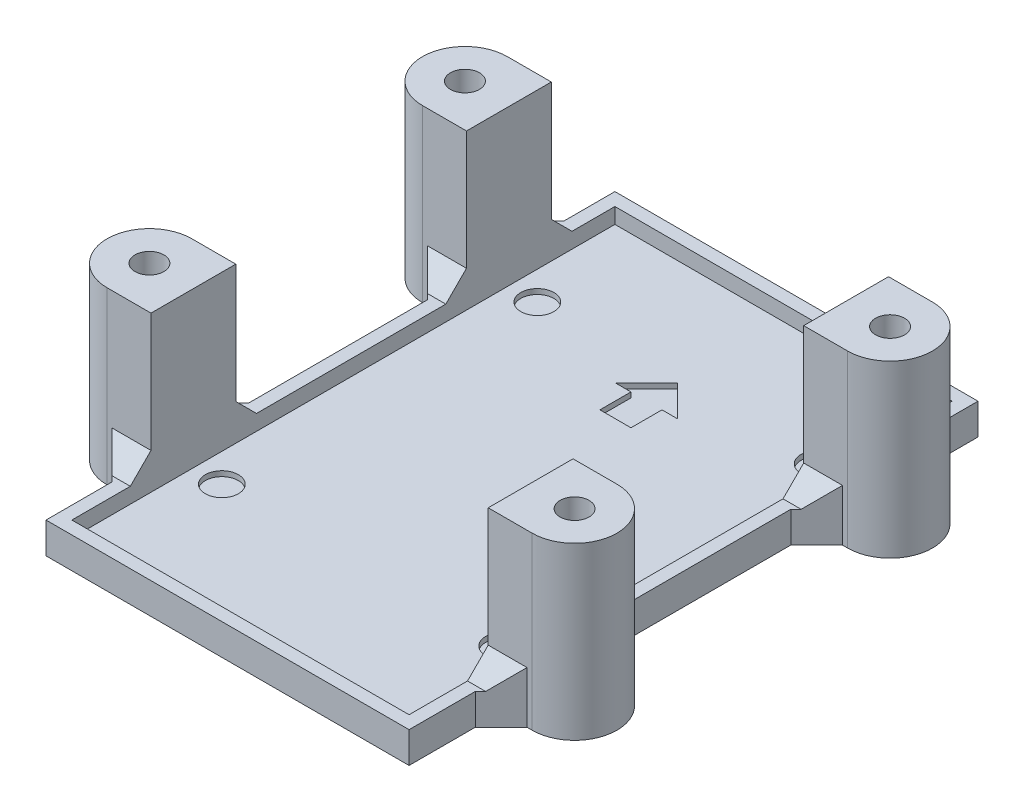
from build123d import *

# Parameters (mm, degrees)
SKETCH2_R               = 1.4
BOSS_EXTRUDE1_DEPTH     = 1.5
SKETCH5_R               = 1.6
CUT_EXTRUDE1_DEPTH      = 0.5
SKETCH3_R               = 1.4
SKETCH3_W               = 32.6
SKETCH3_H               = 52.5
BOSS_EXTRUDE2_DEPTH     = 1.5
SKETCH4_R               = 1.4
BOSS_EXTRUDE3_DEPTH     = 13.5
CHAMFER1_SIZE           = 2
CUT_EXTRUDE2_DEPTH      = 1
CUT_EXTRUDE2_DEPTH_BACK = 2.5


with BuildPart() as part:
    # Sketch2 → Boss-Extrude1 (new body)
    with BuildSketch(Plane(origin=(0, 0, 0), x_dir=(1, 0, 0), z_dir=(0, 1, 0))):
        with BuildLine():
            Line((-1.5, -1.5), (-1.5, 4.9))
            Line((-1.5, 4.9), (-4, 7.4))
            Line((-4, 7.4), (-4.5, 7.4))
            ThreePointArc((-4.5, 7.4), (-8.6, 11.5), (-4.5, 15.6))
            Line((-4.5, 15.6), (-4, 15.6))
            Line((-4, 15.6), (-1.5, 18.1))
            Line((-1.5, 18.1), (-1.5, 35.4))
            Line((-1.5, 35.4), (-4, 37.9))
            Line((-4, 37.9), (-4.5, 37.9))
            ThreePointArc((-4.5, 37.9), (-8.6, 42), (-4.5, 46.1))
            Line((-4.5, 46.1), (-4, 46.1))
            Line((-4, 46.1), (-1.5, 48.6))
            Line((-1.5, 48.6), (-1.5, 53.5))
            Line((-1.5, 53.5), (33.6, 53.5))
            Line((33.6, 53.5), (33.6, 48.6))
            Line((33.6, 48.6), (36.1, 46.1))
            Line((36.1, 46.1), (36.6, 46.1))
            ThreePointArc((36.6, 46.1), (40.7, 42), (36.6, 37.9))
            Line((36.6, 37.9), (36.1, 37.9))
            Line((36.1, 37.9), (33.6, 35.4))
            Line((33.6, 35.4), (33.6, 18.1))
            Line((33.6, 18.1), (36.1, 15.6))
            Line((36.1, 15.6), (36.6, 15.6))
            ThreePointArc((36.6, 15.6), (40.7, 11.5), (36.6, 7.4))
            Line((36.6, 7.4), (36.1, 7.4))
            Line((36.1, 7.4), (33.6, 4.9))
            Line((33.6, 4.9), (33.6, -1.5))
            Line((33.6, -1.5), (-1.5, -1.5))
        make_face()
        with Locations((-4.5, 42)):
            Circle(SKETCH2_R, mode=Mode.SUBTRACT)
        with Locations((-4.5, 11.5)):
            Circle(SKETCH2_R, mode=Mode.SUBTRACT)
        with Locations((36.6, 11.5)):
            Circle(SKETCH2_R, mode=Mode.SUBTRACT)
        with Locations((36.6, 42)):
            Circle(SKETCH2_R, mode=Mode.SUBTRACT)
    extrude(amount=-BOSS_EXTRUDE1_DEPTH)

    # Sketch5 → Cut-Extrude1 (cut)
    with BuildSketch(Plane(origin=(0, 0, 0), x_dir=(1, 0, 0), z_dir=(0, 1, 0))):
        with Locations((2.5, 42)):
            Circle(SKETCH5_R)
        with Locations((29.6, 42)):
            Circle(SKETCH5_R)
        with Locations((29.6, 11.5)):
            Circle(SKETCH5_R)
        with Locations((2.5, 11.5)):
            Circle(SKETCH5_R)
        Polygon((14.55, 36), (17.55, 36), (17.55, 39), (19.05, 39), (16.05, 42), (13.05, 39), (14.55, 39), align=None)
    extrude(amount=-CUT_EXTRUDE1_DEPTH, mode=Mode.SUBTRACT)

    # Sketch3 → Boss-Extrude2 (add)
    with BuildSketch(Plane(origin=(0, 0, 0), x_dir=(1, 0, 0), z_dir=(0, 1, 0))):
        with BuildLine():
            Line((-1.5, 53.5), (33.6, 53.5))
            Line((33.6, 53.5), (33.6, 48.6))
            Line((33.6, 48.6), (36.1, 46.1))
            Line((36.1, 46.1), (36.6, 46.1))
            ThreePointArc((36.6, 46.1), (40.7, 42), (36.6, 37.9))
            Line((36.6, 37.9), (36.1, 37.9))
            Line((36.1, 37.9), (33.6, 35.4))
            Line((33.6, 35.4), (33.6, 18.1))
            Line((33.6, 18.1), (36.1, 15.6))
            Line((36.1, 15.6), (36.6, 15.6))
            ThreePointArc((36.6, 15.6), (40.7, 11.5), (36.6, 7.4))
            Line((36.6, 7.4), (36.1, 7.4))
            Line((36.1, 7.4), (33.6, 4.9))
            Line((33.6, 4.9), (33.6, -1.5))
            Line((33.6, -1.5), (-1.5, -1.5))
            Line((-1.5, -1.5), (-1.5, 4.9))
            Line((-1.5, 4.9), (-4, 7.4))
            Line((-4, 7.4), (-4.5, 7.4))
            ThreePointArc((-4.5, 7.4), (-8.6, 11.5), (-4.5, 15.6))
            Line((-4.5, 15.6), (-4, 15.6))
            Line((-4, 15.6), (-1.5, 18.1))
            Line((-1.5, 18.1), (-1.5, 35.4))
            Line((-1.5, 35.4), (-4, 37.9))
            Line((-4, 37.9), (-4.5, 37.9))
            ThreePointArc((-4.5, 37.9), (-8.6, 42), (-4.5, 46.1))
            Line((-4.5, 46.1), (-4, 46.1))
            Line((-4, 46.1), (-1.5, 48.6))
            Line((-1.5, 48.6), (-1.5, 53.5))
        make_face()
        with Locations((-4.5, 42)):
            Circle(SKETCH3_R, mode=Mode.SUBTRACT)
        with Locations((36.6, 42)):
            Circle(SKETCH3_R, mode=Mode.SUBTRACT)
        with Locations((36.6, 11.5)):
            Circle(SKETCH3_R, mode=Mode.SUBTRACT)
        with Locations((-4.5, 11.5)):
            Circle(SKETCH3_R, mode=Mode.SUBTRACT)
        with Locations((16.05, 26)):
            Rectangle(SKETCH3_W, SKETCH3_H, mode=Mode.SUBTRACT)
    extrude(amount=BOSS_EXTRUDE2_DEPTH)

    # Sketch4 → Boss-Extrude3 (add)
    with BuildSketch(Plane(origin=(0, 1.5, 0), x_dir=(1, 0, 0), z_dir=(0, 1, 0))):
        with BuildLine():
            Line((-4.5, 46.1), (-0.25, 46.1))
            Line((-0.25, 46.1), (-0.25, 37.9))
            Line((-0.25, 37.9), (-4.5, 37.9))
            ThreePointArc((-4.5, 37.9), (-8.6, 42), (-4.5, 46.1))
        make_face()
        with Locations((-4.5, 42)):
            Circle(SKETCH4_R, mode=Mode.SUBTRACT)
        with BuildLine():
            Line((-4.5, 7.4), (-0.25, 7.4))
            Line((-0.25, 7.4), (-0.25, 15.6))
            Line((-0.25, 15.6), (-4.5, 15.6))
            ThreePointArc((-4.5, 15.6), (-8.6, 11.5), (-4.5, 7.4))
        make_face()
        with Locations((-4.5, 11.5)):
            Circle(SKETCH4_R, mode=Mode.SUBTRACT)
        with BuildLine():
            Line((32.35, 15.6), (32.35, 7.4))
            Line((32.35, 7.4), (36.6, 7.4))
            ThreePointArc((36.6, 7.4), (40.7, 11.5), (36.6, 15.6))
            Line((36.6, 15.6), (32.35, 15.6))
        make_face()
        with Locations((36.6, 11.5)):
            Circle(SKETCH4_R, mode=Mode.SUBTRACT)
        with BuildLine():
            Line((32.35, 46.1), (36.6, 46.1))
            ThreePointArc((36.6, 46.1), (40.7, 42), (36.6, 37.9))
            Line((36.6, 37.9), (32.35, 37.9))
            Line((32.35, 37.9), (32.35, 46.1))
        make_face()
        with Locations((36.6, 42)):
            Circle(SKETCH4_R, mode=Mode.SUBTRACT)
    extrude(amount=BOSS_EXTRUDE3_DEPTH)

    # Chamfer1
    chamfer1_edges = [part.edges().sort_by_distance(p)[0] for p in [
        (34.225, 1.5, -37.9),
        (34.225, 1.5, -46.1),
        (34.225, 1.5, -15.6),
        (34.225, 1.5, -7.4),
        (-2.125, 1.5, -7.4),
        (-2.125, 1.5, -15.6),
        (-2.125, 1.5, -37.9),
        (-2.125, 1.5, -46.1),
    ]]
    chamfer(chamfer1_edges, length=CHAMFER1_SIZE)

    # Sketch6 → Cut-Extrude2 (cut, two sides)
    with BuildSketch(Plane.XZ.offset(1.5)) as cut_extrude2_sk:
        Polygon((-1.266838493, -42), (-2.883419246, -39.2), (-6.116580754, -39.2), (-7.733161507, -42), (-6.116580754, -44.8), (-2.883419246, -44.8), align=None)
        Polygon((33.366838493, -42), (34.983419246, -44.8), (38.216580754, -44.8), (39.833161507, -42), (38.216580754, -39.2), (34.983419246, -39.2), align=None)
        Polygon((-1.266838493, -11.5), (-2.883419246, -8.7), (-6.116580754, -8.7), (-7.733161507, -11.5), (-6.116580754, -14.3), (-2.883419246, -14.3), align=None)
        Polygon((33.366838493, -11.5), (34.983419246, -14.3), (38.216580754, -14.3), (39.833161507, -11.5), (38.216580754, -8.7), (34.983419246, -8.7), align=None)
    extrude(amount=CUT_EXTRUDE2_DEPTH, mode=Mode.SUBTRACT)
    extrude(cut_extrude2_sk.sketch, amount=-CUT_EXTRUDE2_DEPTH_BACK, mode=Mode.SUBTRACT)


solid = part.part
